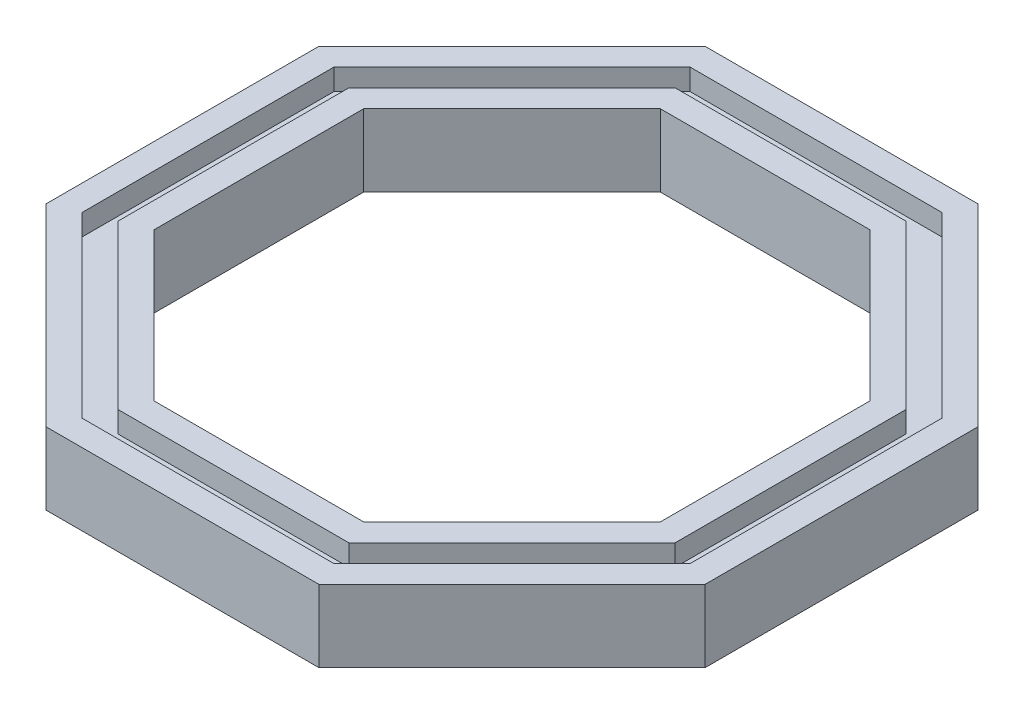
from build123d import *

# Parameters (mm, degrees)
EXTRUDE_1_DEPTH     = 3.4
CUT_EXTRUDE_1_DEPTH = 1


with BuildPart() as part:
    # 스케치1 → 보스-돌출1 (new body)
    with BuildSketch(Plane(origin=(0, 0, 0), x_dir=(1, 0, 0), z_dir=(0, 1, 0))):
        Polygon((-15.520132754, -6.428649477), (-6.428649477, -15.520132754), (6.428649477, -15.520132754), (15.520132754, -6.428649477), (15.520132754, 6.428649477), (6.428649477, 15.520132754), (-6.428649477, 15.520132754), (-15.520132754, 6.428649477), align=None)
        Polygon((-5.931593202, -14.320132754), (5.931593202, -14.320132754), (14.320132754, -5.931593202), (14.320132754, 5.931593202), (5.931593202, 14.320132754), (-5.931593202, 14.320132754), (-14.320132754, 5.931593202), (-14.320132754, -5.931593202), align=None, mode=Mode.SUBTRACT)
        Polygon((-14.320132754, -5.931593202), (-5.931593202, -14.320132754), (5.931593202, -14.320132754), (14.320132754, -5.931593202), (14.320132754, 5.931593202), (5.931593202, 14.320132754), (-5.931593202, 14.320132754), (-14.320132754, 5.931593202), align=None)
        Polygon((-5.434536927, -13.120132754), (5.434536927, -13.120132754), (13.120132754, -5.434536927), (13.120132754, 5.434536927), (5.434536927, 13.120132754), (-5.434536927, 13.120132754), (-13.120132754, 5.434536927), (-13.120132754, -5.434536927), align=None, mode=Mode.SUBTRACT)
        Polygon((-13.120132754, -5.434536927), (-5.434536927, -13.120132754), (5.434536927, -13.120132754), (13.120132754, -5.434536927), (13.120132754, 5.434536927), (5.434536927, 13.120132754), (-5.434536927, 13.120132754), (-13.120132754, 5.434536927), align=None)
        Polygon((-4.937480652, -11.920132754), (4.937480652, -11.920132754), (11.920132754, -4.937480652), (11.920132754, 4.937480652), (4.937480652, 11.920132754), (-4.937480652, 11.920132754), (-11.920132754, 4.937480652), (-11.920132754, -4.937480652), align=None, mode=Mode.SUBTRACT)
    extrude(amount=EXTRUDE_1_DEPTH)

    # 스케치3 → 컷-돌출1 (cut)
    with BuildSketch(Plane(origin=(0, 3.4, 0), x_dir=(1, 0, 0), z_dir=(0, 1, 0))):
        Polygon((-14.320132754, -5.931593202), (-5.931593202, -14.320132754), (5.931593202, -14.320132754), (14.320132754, -5.931593202), (14.320132754, 5.931593202), (5.931593202, 14.320132754), (-5.931593202, 14.320132754), (-14.320132754, 5.931593202), align=None)
        Polygon((-13.120132754, -5.434536927), (-5.434536927, -13.120132754), (5.434536927, -13.120132754), (13.120132754, -5.434536927), (13.120132754, 5.434536927), (5.434536927, 13.120132754), (-5.434536927, 13.120132754), (-13.120132754, 5.434536927), align=None, mode=Mode.SUBTRACT)
    cut_extrude_1 = extrude(amount=-CUT_EXTRUDE_1_DEPTH, mode=Mode.SUBTRACT)

    # 대칭 복사1: 컷-돌출1 across plane
    add(cut_extrude_1.mirror(Plane.ZX.offset(1.7)), mode=Mode.SUBTRACT)


solid = part.part
